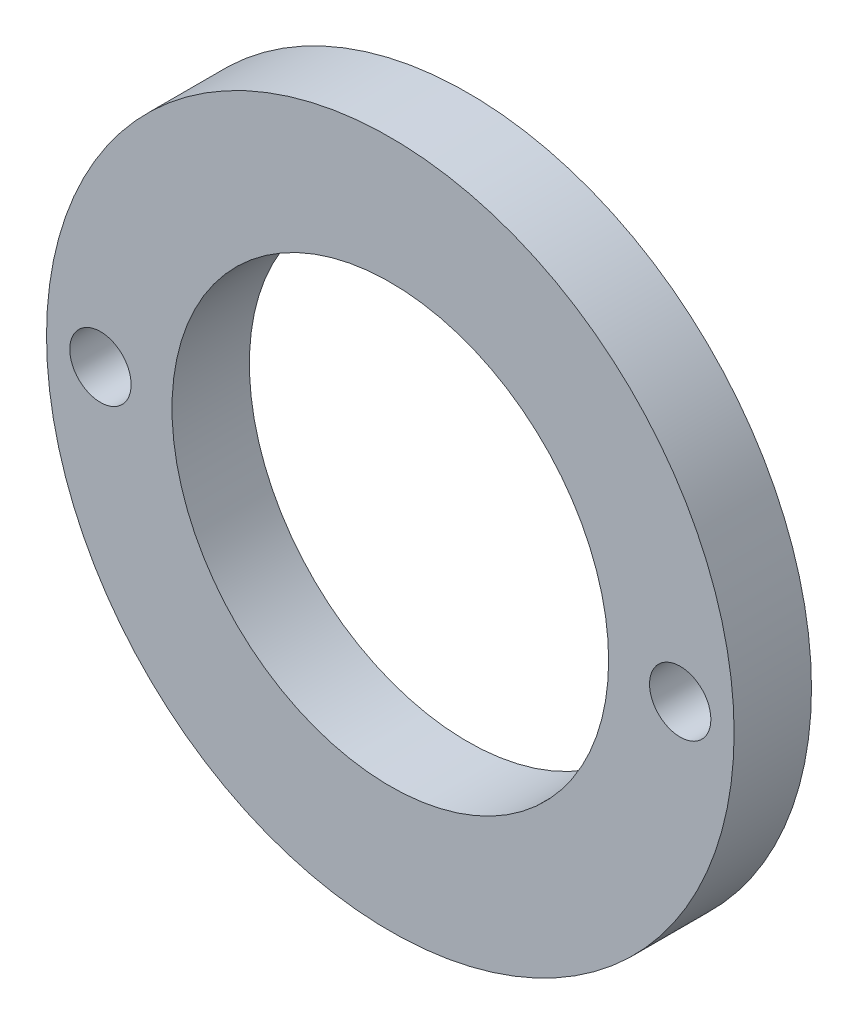
from build123d import *

# Parameters (mm, degrees)
SKETCH1_R                    = 20
SKETCH1_R_2                  = 12.7
BOSS_EXTRUDE1_DEPTH          = 4.5
F_28_0_1405_DIAMETER_HOLE1_D = 3.5687


with BuildPart() as part:
    # Sketch1 → Boss-Extrude1 (new body)
    with BuildSketch(Plane.XY):
        Circle(SKETCH1_R)
        Circle(SKETCH1_R_2, mode=Mode.SUBTRACT)
    extrude(amount=BOSS_EXTRUDE1_DEPTH)

    # #28 (0.1405) Diameter Hole1 (through all)
    with Locations(Plane.XY.offset(4.5)):
        with Locations((-16.862709614, 0), (16.862709614, 0)):
            Hole(F_28_0_1405_DIAMETER_HOLE1_D / 2)


solid = part.part
